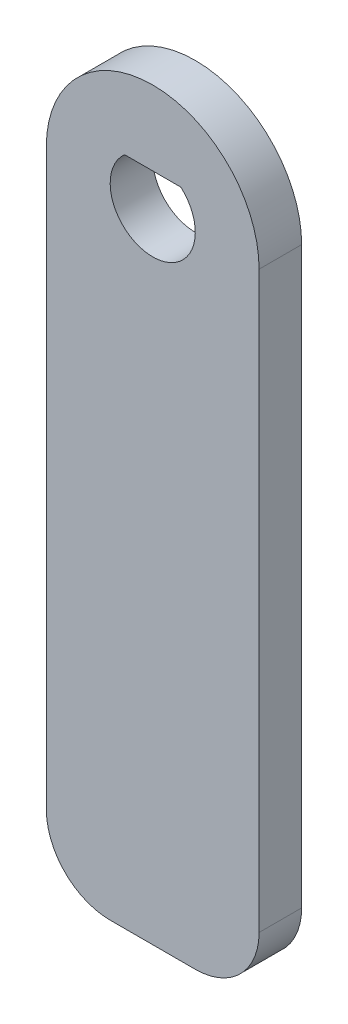
from build123d import *

# Parameters (mm, degrees)
BOSS_EXTRUDE1_DEPTH = 2


with BuildPart() as part:
    # Sketch1 → Boss-Extrude1 (new body)
    with BuildSketch(Plane.XY):
        with BuildLine():
            Line((-5, 0), (-5, -27))
            ThreePointArc((-5, -27), (-4.121320344, -29.121320344), (-2, -30))
            Line((-2, -30), (2, -30))
            ThreePointArc((2, -30), (4.121320344, -29.121320344), (5, -27))
            Line((5, -27), (5, 0))
            ThreePointArc((5, 0), (0, 5), (-5, 0))
        make_face()
        with BuildLine():
            Line((-1.322875656, 1.5), (1.322875656, 1.5))
            ThreePointArc((1.322875656, 1.5), (0, -2), (-1.322875656, 1.5))
        make_face(mode=Mode.SUBTRACT)
    extrude(amount=BOSS_EXTRUDE1_DEPTH)


solid = part.part
